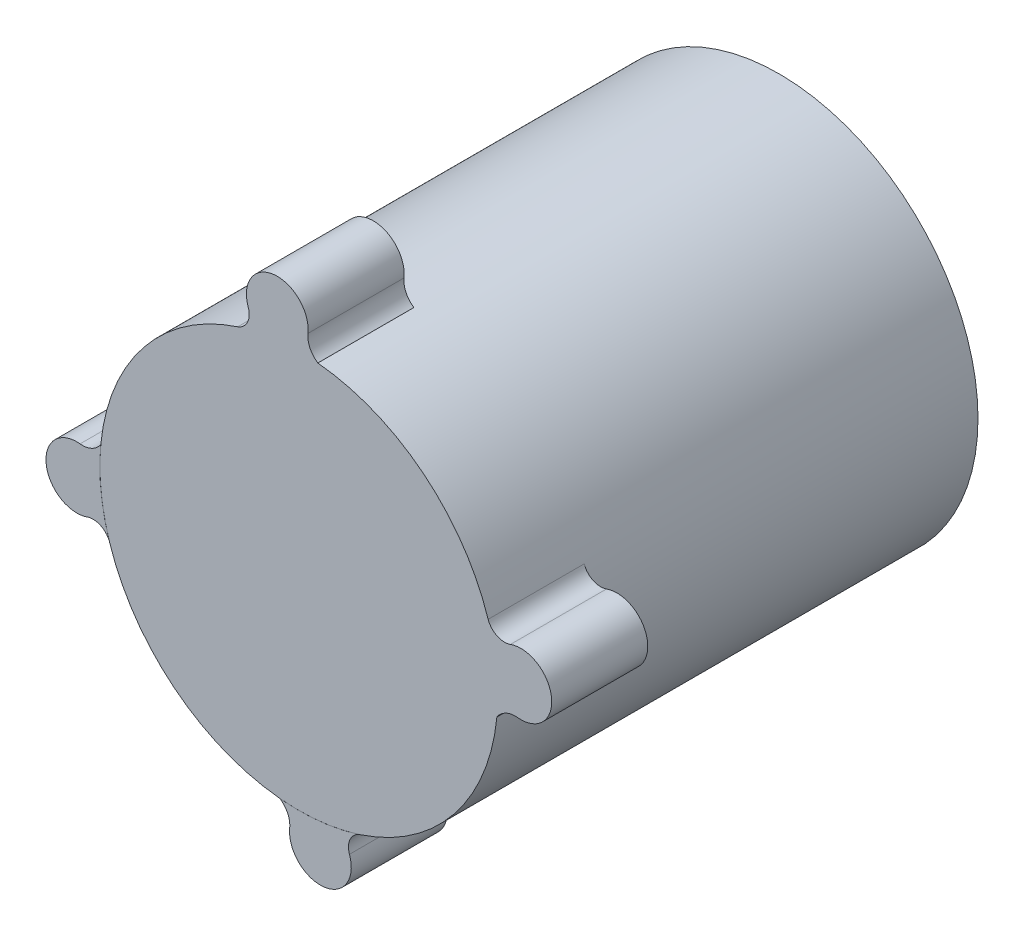
from build123d import *

# Parameters (mm, degrees)
SZKIC1_R                    = 29
DODANIE_WYCI_GNI_CIE1_DEPTH = 70
DODANIE_WYCI_GNI_CIE4_DEPTH = 14


with BuildPart() as part:
    # Szkic1 → Dodanie-wyciągnięcie1 (new body)
    with BuildSketch(Plane.XY):
        Circle(SZKIC1_R)
    extrude(amount=DODANIE_WYCI_GNI_CIE1_DEPTH)

    # Szkic2 → Dodanie-wyciągnięcie4 (add)
    with BuildSketch(Plane.XY.offset(70)):
        with BuildLine():
            ThreePointArc((30.84790374, 7.380401745), (28.900861272, 7.476956762), (27.593197744, 8.922748358))
            ThreePointArc((27.593197744, 8.922748358), (28.64614053, 4.516484552), (29, 0))
            ThreePointArc((29, 0), (28.966113998, -1.401513415), (28.864535183, -2.799751542))
            Line((28.864535183, -2.799751542), (28.877094392, -2.755388077))
            ThreePointArc((28.877094392, -2.755388077), (30.18274059, -1.620828188), (31.888121854, -1.331669269))
            ThreePointArc((31.888121854, -1.331669269), (36.831424825, 3.67669565), (30.84790374, 7.380401745))
        make_face()
        with BuildLine():
            ThreePointArc((7.380401745, -30.84790374), (7.4552326, -28.947937345), (8.825804257, -27.62998238))
            ThreePointArc((8.825804257, -27.62998238), (3.098462136, -28.840941336), (-2.755388077, -28.877094392))
            ThreePointArc((-2.755388077, -28.877094392), (-1.620828188, -30.18274059), (-1.331669269, -31.888121854))
            ThreePointArc((-1.331669269, -31.888121854), (3.67669565, -36.831424825), (7.380401745, -30.84790374))
        make_face()
        with BuildLine():
            ThreePointArc((-27.651486159, -8.774084684), (-28.846317681, -3.071219093), (-28.877094392, 2.755388077))
            ThreePointArc((-28.877094392, 2.755388077), (-30.18274059, 1.620828188), (-31.888121854, 1.331669269))
            ThreePointArc((-31.888121854, 1.331669269), (-36.831424825, -3.67669565), (-30.84790374, -7.380401745))
            ThreePointArc((-30.84790374, -7.380401745), (-28.973547583, -7.443898089), (-27.651486159, -8.774084684))
        make_face()
        with BuildLine():
            Line((2.770143564, 28.867391719), (2.755388077, 28.877094392))
            ThreePointArc((2.755388077, 28.877094392), (1.620828188, 30.18274059), (1.331669269, 31.888121854))
            ThreePointArc((1.331669269, 31.888121854), (-3.67669565, 36.831424825), (-7.380401745, 30.84790374))
            ThreePointArc((-7.380401745, 30.84790374), (-7.476956762, 28.900861272), (-8.922748358, 27.593197744))
            ThreePointArc((-8.922748358, 27.593197744), (-3.141580654, 28.829333516), (2.770143564, 28.867391719))
        make_face()
    extrude(amount=-DODANIE_WYCI_GNI_CIE4_DEPTH)


solid = part.part
